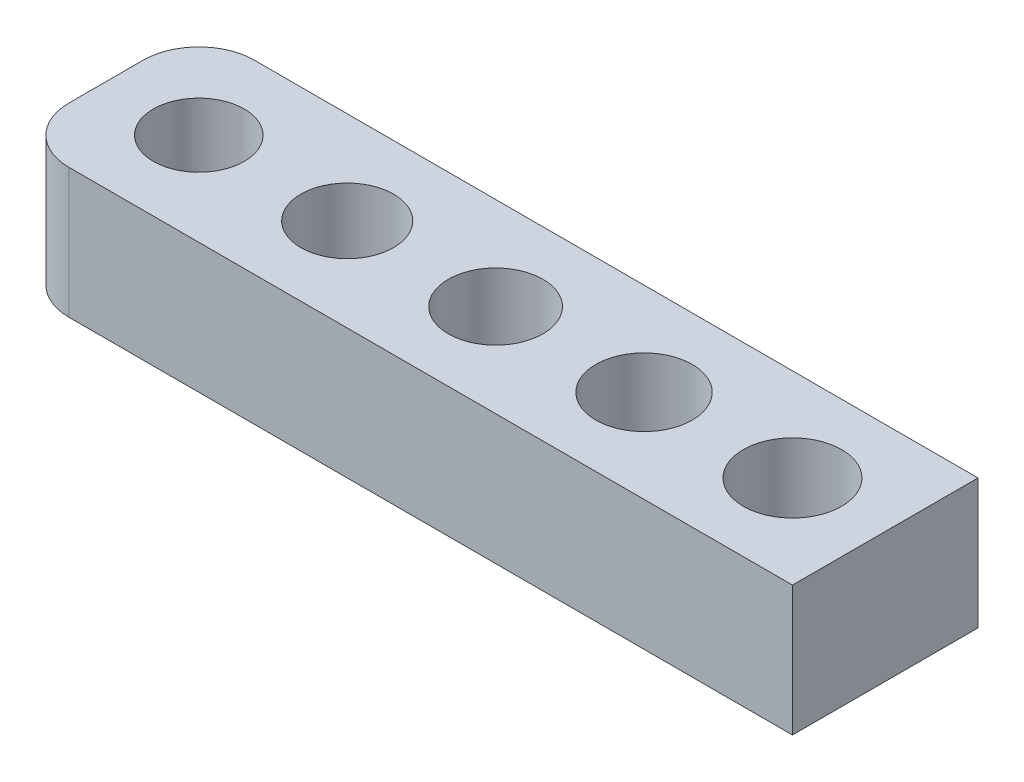
from build123d import *

# Parameters (mm, degrees)
SKETCH1_W           = 42
SKETCH1_H           = 10
SKETCH1_R           = 2.45
SKETCH1_R_2         = 2.5
SKETCH1_R_3         = 2.55
SKETCH1_R_4         = 2.6
SKETCH1_R_5         = 2.65
BOSS_EXTRUDE1_DEPTH = 7
FILLET2_R           = 3


with BuildPart() as part:
    # Sketch1 → Boss-Extrude1 (new body)
    with BuildSketch(Plane(origin=(0, 0, 0), x_dir=(1, 0, 0), z_dir=(0, 1, 0))):
        with Locations((16, 0)):
            Rectangle(SKETCH1_W, SKETCH1_H)
        Circle(SKETCH1_R, mode=Mode.SUBTRACT)
        with Locations((8, 0)):
            Circle(SKETCH1_R_2, mode=Mode.SUBTRACT)
        with Locations((16, 0)):
            Circle(SKETCH1_R_3, mode=Mode.SUBTRACT)
        with Locations((24, 0)):
            Circle(SKETCH1_R_4, mode=Mode.SUBTRACT)
        with Locations((32, 0)):
            Circle(SKETCH1_R_5, mode=Mode.SUBTRACT)
    extrude(amount=BOSS_EXTRUDE1_DEPTH)

    # Fillet2
    fillet2_edges = [part.edges().sort_by_distance(p)[0] for p in [
        (-5, 3.5, 5),
        (-5, 3.5, -5),
    ]]
    fillet(fillet2_edges, radius=FILLET2_R)


solid = part.part
